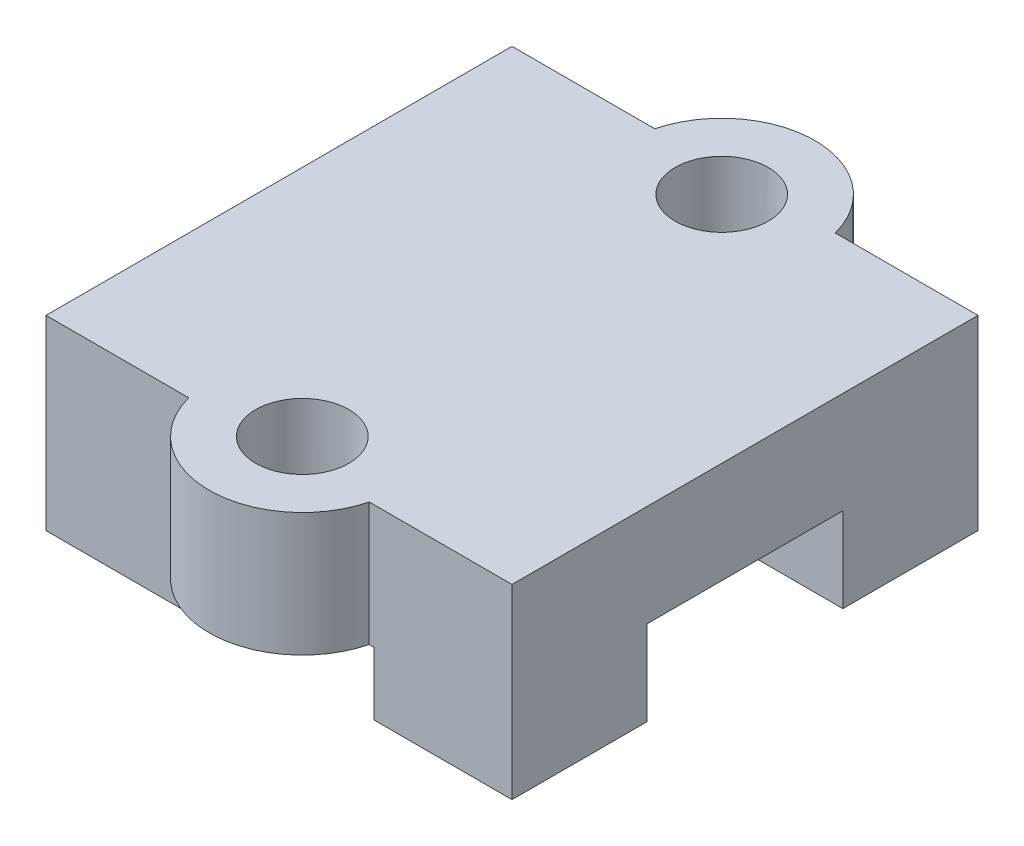
from build123d import *

# Parameters (mm, degrees)
EXTRUDE_1_DEPTH      = 10
EXTRUDE_1_DEPTH_BACK = 10
SKETCH_3_R           = 4
EXTRUDE_2_DEPTH      = 8
SKETCH_2_R           = 2
CUT_EXTRUDE_1_DEPTH  = 10
SKETCH_4_R           = 4.2
SKETCH_4_R_2         = 2
CUT_EXTRUDE_2_DEPTH  = 2.7


with BuildPart() as part:
    # Sketch 1 → Extrude 1 (new body, two sides)
    with BuildSketch(Plane(origin=(-110, 0, 0), x_dir=(0, 0, -1), z_dir=(1, 0, 0))) as extrude_1_sk:
        Polygon((-4.2, -5), (-4.2, -1.3625), (4.2, -1.3625), (4.2, -5), (10, -5), (10, 3), (-10, 3), (-10, -5), align=None)
    extrude(amount=EXTRUDE_1_DEPTH)
    extrude(extrude_1_sk.sketch, amount=-EXTRUDE_1_DEPTH_BACK)

    # Sketch 3 → Extrude 2 (add, through all)
    with BuildSketch(Plane(origin=(0, 3, 0), x_dir=(1, 0, 0), z_dir=(0, 1, 0))):
        with Locations((-110, -9)):
            Circle(SKETCH_3_R)
        with Locations((-110, 9)):
            Circle(SKETCH_3_R)
    extrude(amount=-EXTRUDE_2_DEPTH)

    # Sketch 2 → Cut-Extrude 1 (cut)
    with BuildSketch(Plane(origin=(0, 3, 0), x_dir=(1, 0, 0), z_dir=(0, 1, 0))):
        with Locations((-110, -9)):
            Circle(SKETCH_2_R)
        with Locations((-110, 9)):
            Circle(SKETCH_2_R)
    extrude(amount=-CUT_EXTRUDE_1_DEPTH, mode=Mode.SUBTRACT)

    # Sketch 4 → Cut-Extrude 2 (cut)
    with BuildSketch(Plane.XZ.offset(5)):
        with Locations((-110, 9)):
            Circle(SKETCH_4_R)
        with Locations((-110, 9)):
            Circle(SKETCH_4_R_2, mode=Mode.SUBTRACT)
        with Locations((-110, -9)):
            Circle(SKETCH_4_R)
        with Locations((-110, -9)):
            Circle(SKETCH_4_R_2, mode=Mode.SUBTRACT)
    extrude(amount=-CUT_EXTRUDE_2_DEPTH, mode=Mode.SUBTRACT)


solid = part.part
